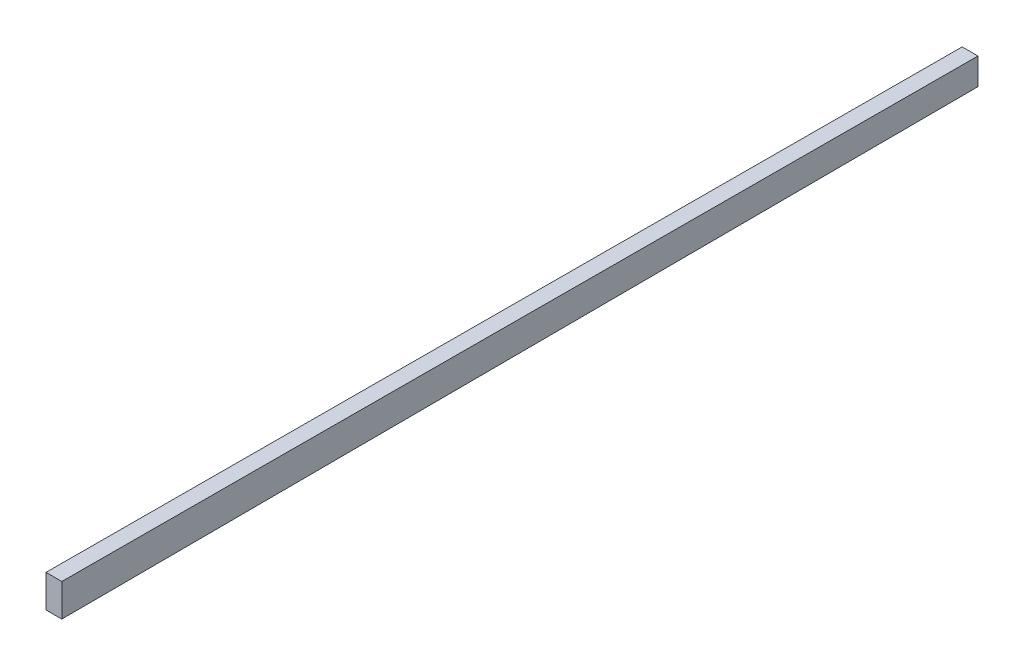
from build123d import *


with BuildPart() as part:
    # Sketch1 → Loft1 section 0
    with BuildSketch(Plane.XY):
        with BuildLine():
            Line((-3.175, -5.334), (3.175, -5.334))
            Line((3.175, -5.334), (3.175, 5.334))
            Line((3.175, 5.334), (-3.175, 5.334))
            Line((-3.175, 5.334), (-3.175, -5.334))
        make_face()
    # Sketch2 → Loft1 section 1
    with BuildSketch(Plane.XY.offset(368.3)):
        with BuildLine():
            Line((-3.175, -6.5532), (3.175, -6.5532))
            Line((3.175, -6.5532), (3.175, 6.5532))
            Line((3.175, 6.5532), (-3.175, 6.5532))
            Line((-3.175, 6.5532), (-3.175, -6.5532))
        make_face()
    loft()


solid = part.part
